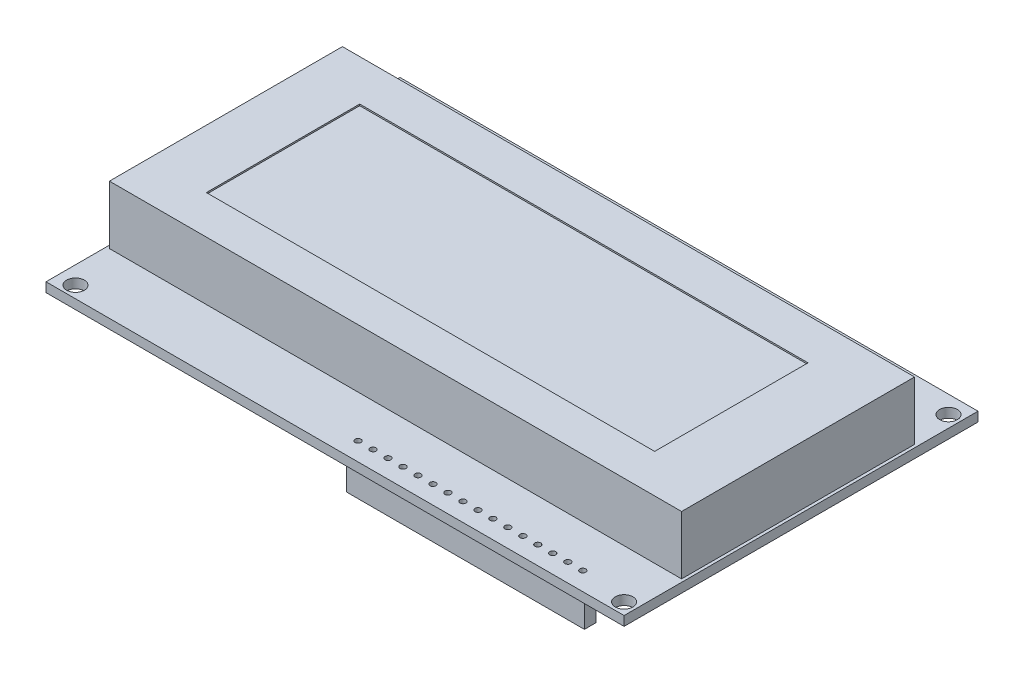
from build123d import *

# Parameters (mm, degrees)
SKETCH1_W           = 98
SKETCH1_H           = 60
BOSS_EXTRUDE1_DEPTH = 1.6
SKETCH2_W           = 97
SKETCH2_H           = 39.5
BOSS_EXTRUDE2_DEPTH = 9.9
SKETCH4_R           = 1.5
CUT_EXTRUDE1_DEPTH  = 1.6
SKETCH5_R           = 0.5
CUT_EXTRUDE2_DEPTH  = 1.6
SKETCH6_W           = 40.313195669
SKETCH6_H           = 1.990775095
BOSS_EXTRUDE3_DEPTH = 6
SKETCH3_W           = 76
SKETCH3_H           = 26
CUT_EXTRUDE3_DEPTH  = 0.254


with BuildPart() as part:
    # Sketch1 → Boss-Extrude1 (new body)
    with BuildSketch(Plane(origin=(0, 0, 0), x_dir=(1, 0, 0), z_dir=(0, 1, 0))):
        with Locations((-23.16287695, -6.675720991)):
            Rectangle(SKETCH1_W, SKETCH1_H)
    extrude(amount=BOSS_EXTRUDE1_DEPTH)

    # Sketch2 → Boss-Extrude2 (add)
    with BuildSketch(Plane(origin=(0, 1.6, 0), x_dir=(1, 0, 0), z_dir=(0, 1, 0))):
        with Locations((-23.16287695, -6.675720991)):
            Rectangle(SKETCH2_W, SKETCH2_H)
    extrude(amount=BOSS_EXTRUDE2_DEPTH)

    # Sketch4 → Cut-Extrude1 (cut)
    with BuildSketch(Plane(origin=(0, 1.6, 0), x_dir=(1, 0, 0), z_dir=(0, 1, 0))):
        with Locations((-69.16287695, -34.675720991)):
            Circle(SKETCH4_R)
        with Locations((23.83712305, -34.675720991)):
            Circle(SKETCH4_R)
        with Locations((-69.16287695, 20.324279009)):
            Circle(SKETCH4_R)
        with Locations((23.83712305, 20.324279009)):
            Circle(SKETCH4_R)
    extrude(amount=-CUT_EXTRUDE1_DEPTH, mode=Mode.SUBTRACT)

    # Sketch5 → Cut-Extrude2 (cut)
    with BuildSketch(Plane(origin=(0, 1.6, 0), x_dir=(1, 0, 0), z_dir=(0, 1, 0))):
        with Locations((15.73712305, -33.575720991)):
            Circle(SKETCH5_R)
        with Locations((13.19712305, -33.575720991)):
            Circle(SKETCH5_R)
        with Locations((10.65712305, -33.575720991)):
            Circle(SKETCH5_R)
        with Locations((8.11712305, -33.575720991)):
            Circle(SKETCH5_R)
        with Locations((5.57712305, -33.575720991)):
            Circle(SKETCH5_R)
        with Locations((3.03712305, -33.575720991)):
            Circle(SKETCH5_R)
        with Locations((0.49712305, -33.575720991)):
            Circle(SKETCH5_R)
        with Locations((-2.04287695, -33.575720991)):
            Circle(SKETCH5_R)
        with Locations((-4.58287695, -33.575720991)):
            Circle(SKETCH5_R)
        with Locations((-7.12287695, -33.575720991)):
            Circle(SKETCH5_R)
        with Locations((-9.66287695, -33.575720991)):
            Circle(SKETCH5_R)
        with Locations((-12.20287695, -33.575720991)):
            Circle(SKETCH5_R)
        with Locations((-14.74287695, -33.575720991)):
            Circle(SKETCH5_R)
        with Locations((-17.28287695, -33.575720991)):
            Circle(SKETCH5_R)
        with Locations((-19.82287695, -33.575720991)):
            Circle(SKETCH5_R)
        with Locations((-22.36287695, -33.575720991)):
            Circle(SKETCH5_R)
    extrude(amount=-CUT_EXTRUDE2_DEPTH, mode=Mode.SUBTRACT)

    # Sketch6 → Boss-Extrude3 (add)
    with BuildSketch(Plane.XZ):
        with Locations((-3.241605768, 33.478976188)):
            Rectangle(SKETCH6_W, SKETCH6_H)
    extrude(amount=BOSS_EXTRUDE3_DEPTH)

    # Sketch3 → Cut-Extrude3 (cut)
    with BuildSketch(Plane(origin=(0, 11.5, 0), x_dir=(1, 0, 0), z_dir=(0, 1, 0))):
        with Locations((-23.766549937, -6.888251248)):
            Rectangle(SKETCH3_W, SKETCH3_H)
    extrude(amount=-CUT_EXTRUDE3_DEPTH, mode=Mode.SUBTRACT)


solid = part.part
